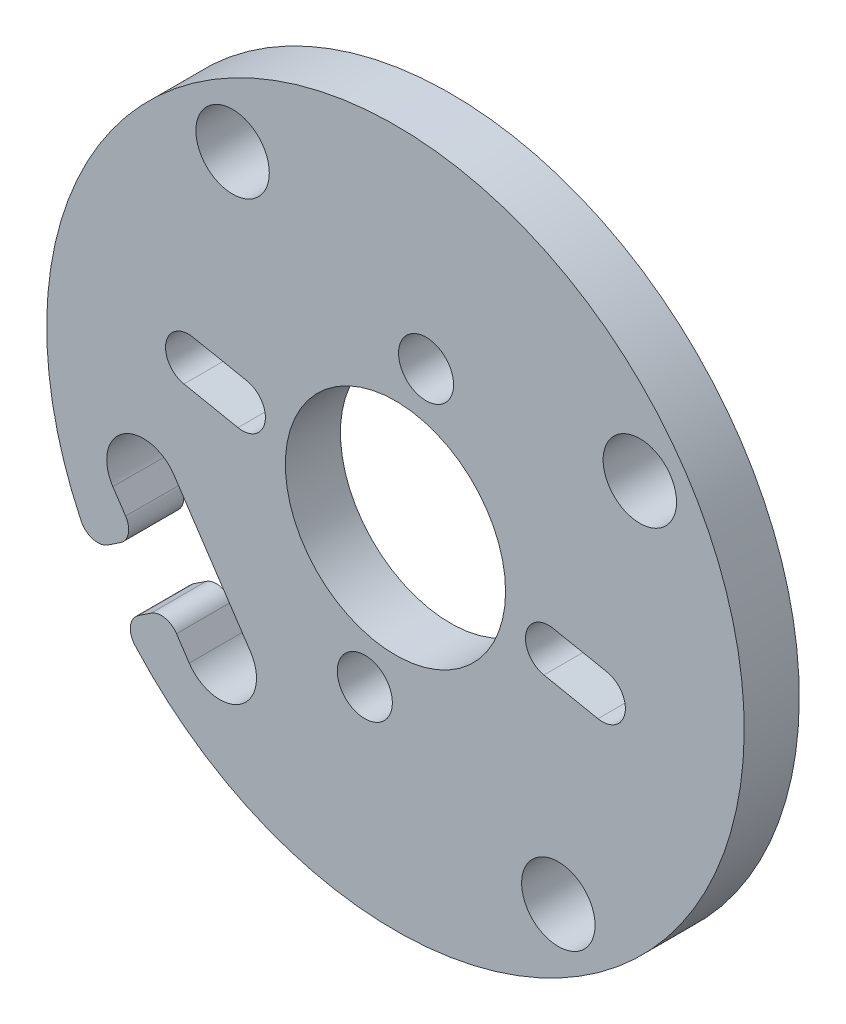
from build123d import *

# Parameters (mm, degrees)
SKETCH1_R           = 2
SKETCH1_R_2         = 6
SKETCH1_R_3         = 1.5
BOSS_EXTRUDE1_DEPTH = 3


with BuildPart() as part:
    # Sketch1 → Boss-Extrude1 (new body)
    with BuildSketch(Plane.XY):
        with BuildLine():
            Line((-12.06516619, -3.534722735), (-7.905685951, -9.775614029))
            ThreePointArc((-7.905685951, -9.775614029), (-8.460728899, -12.549046438), (-11.234161307, -11.99400349))
            Line((-11.234161307, -11.99400349), (-11.927408014, -10.953854941))
            ThreePointArc((-11.927408014, -10.953854941), (-12.563289537, -10.527895875), (-13.314124218, -10.676333467))
            Line((-13.314124218, -10.676333467), (-14.001074492, -11.1341777))
            ThreePointArc((-14.001074492, -11.1341777), (-14.438315509, -11.838795077), (-14.193503634, -12.631090792))
            ThreePointArc((-14.193503634, -12.631090792), (15.810257944, 10.537349939), (-17.120545284, -8.239352474))
            ThreePointArc((-17.120545284, -8.239352474), (-16.483484999, -8.770219263), (-15.664866588, -8.637821183))
            Line((-15.664866588, -8.637821183), (-14.977916314, -8.17997695))
            ThreePointArc((-14.977916314, -8.17997695), (-14.551957247, -7.544095427), (-14.70039484, -6.793260745))
            Line((-14.70039484, -6.793260745), (-15.393641546, -5.753112196))
            ThreePointArc((-15.393641546, -5.753112196), (-14.838598598, -2.979679788), (-12.06516619, -3.534722735))
        make_face()
        with Locations((-8.873557843, 13.313901427)):
            Circle(SKETCH1_R, mode=Mode.SUBTRACT)
        with Locations((13.31390139, 8.873557851)):
            Circle(SKETCH1_R, mode=Mode.SUBTRACT)
        with Locations((8.873557814, -13.313901383)):
            Circle(SKETCH1_R, mode=Mode.SUBTRACT)
        Circle(SKETCH1_R_2, mode=Mode.SUBTRACT)
        with Locations((1.668017187, 8.334729669)):
            Circle(SKETCH1_R_3, mode=Mode.SUBTRACT)
        with Locations((-1.668017187, -8.334729669)):
            Circle(SKETCH1_R_3, mode=Mode.SUBTRACT)
        with BuildLine():
            Line((-11.031102319, 3.482424676), (-8.089433024, 2.893712727))
            ThreePointArc((-8.089433024, 2.893712727), (-7.10903413, 1.422720542), (-8.580026315, 0.442321648))
            Line((-8.580026315, 0.442321648), (-11.52169561, 1.031033596))
            ThreePointArc((-11.52169561, 1.031033596), (-12.502094504, 2.502025781), (-11.031102319, 3.482424676))
        make_face(mode=Mode.SUBTRACT)
        with BuildLine():
            Line((11.03081381, -3.483353645), (8.089191886, -2.894405046))
            ThreePointArc((8.089191886, -2.894405046), (7.108911333, -1.423333995), (8.579982384, -0.443053442))
            Line((8.579982384, -0.443053442), (11.521604309, -1.032002041))
            ThreePointArc((11.521604309, -1.032002041), (12.501884862, -2.503073092), (11.03081381, -3.483353645))
        make_face(mode=Mode.SUBTRACT)
    extrude(amount=BOSS_EXTRUDE1_DEPTH)


solid = part.part
